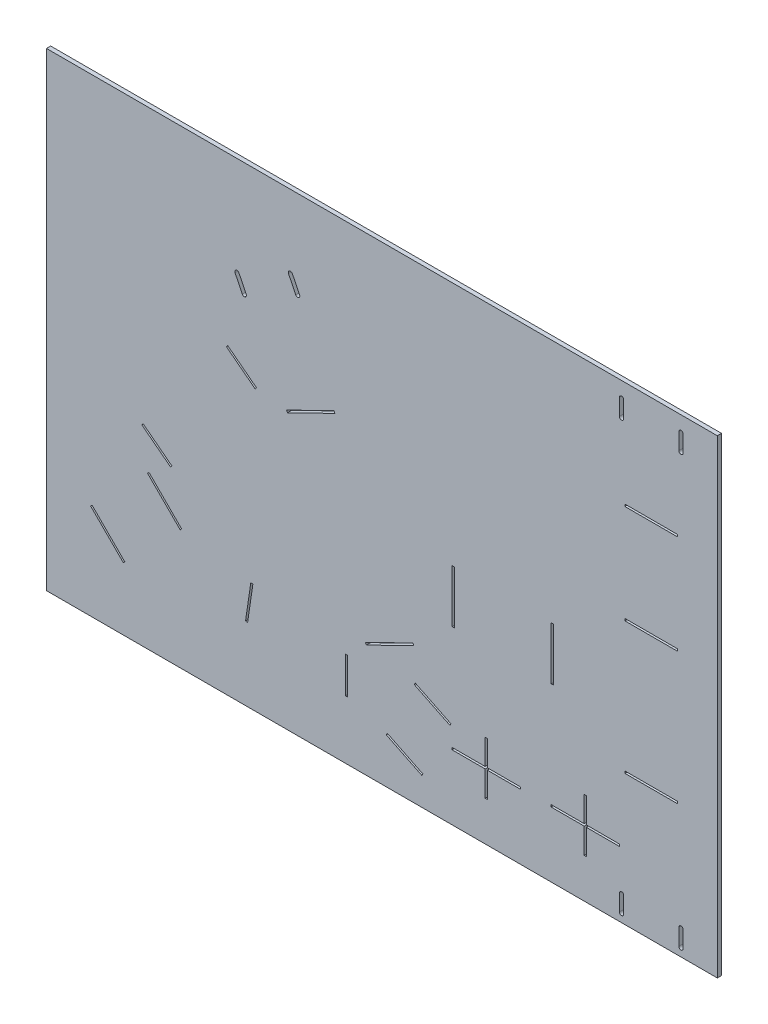
from build123d import *

# Parameters (mm, degrees)
SKETCH1_W           = 1016
SKETCH1_H           = 711.2
BOSS_EXTRUDE1_DEPTH = 6.35
SKETCH2_W           = 80
SKETCH2_H           = 3.175
SKETCH2_W_2         = 3.175
SKETCH2_H_2         = 80
CUT_EXTRUDE1_DEPTH  = 6.35
SKETCH3_W           = 50
SKETCH3_H           = 3.175
CUT_EXTRUDE2_DEPTH  = 10
CUT_EXTRUDE3_DEPTH  = 7.35
CUT_EXTRUDE4_DEPTH  = 7.35
CUT_EXTRUDE5_DEPTH  = 7.35
SKETCH8_W           = 3.175
SKETCH8_H           = 55
CUT_EXTRUDE6_DEPTH  = 7.35


with BuildPart() as part:
    # Sketch1 → Boss-Extrude1 (new body)
    with BuildSketch(Plane.XY):
        with Locations((508, -355.6)):
            Rectangle(SKETCH1_W, SKETCH1_H)
    extrude(amount=BOSS_EXTRUDE1_DEPTH)

    # Sketch2 → Cut-Extrude1 (cut)
    with BuildSketch(Plane.XY.offset(6.35)):
        with Locations((916, -161.2)):
            Rectangle(SKETCH2_W, SKETCH2_H)
        with Locations((916, -311.2)):
            Rectangle(SKETCH2_W, SKETCH2_H)
        with Locations((916, -511.2)):
            Rectangle(SKETCH2_W, SKETCH2_H)
        with Locations((766, -411.2)):
            Rectangle(SKETCH2_W_2, SKETCH2_H_2)
        with Locations((616, -411.2)):
            Rectangle(SKETCH2_W_2, SKETCH2_H_2)
        with BuildLine():
            Line((874.25, -673.7), (874.25, -698.7))
            ThreePointArc((874.25, -698.7), (871, -701.95), (867.75, -698.7))
            Line((867.75, -698.7), (867.75, -673.7))
            ThreePointArc((867.75, -673.7), (871, -670.45), (874.25, -673.7))
        make_face()
        Polygon((363.596651934, -292.488903378), (435.500175638, -257.419211635), (436.892004029, -260.272882732), (364.988480325, -295.342574475), align=None)
        Polygon((483.061726987, -537.428605693), (554.965250691, -502.35891395), (556.357079082, -505.212585047), (484.453555378, -540.28227679), align=None)
        with Locations((816, -611.2)):
            Rectangle(SKETCH2_W_2, SKETCH2_H_2)
        with Locations((666, -611.2)):
            Rectangle(SKETCH2_W_2, SKETCH2_H_2)
        Polygon((558.501253664, -553.109163281), (612.428896442, -579.411432089), (611.037068051, -582.265103186), (557.109425273, -555.962834378), align=None)
        Polygon((516.055967376, -640.134896814), (569.983610154, -666.437165622), (568.591781763, -669.290836719), (514.664138985, -642.988567911), align=None)
        Polygon((69.138539017, -564.561537688), (118.6360137, -614.059012371), (116.39094967, -616.304076401), (66.893474987, -566.806601718), align=None)
        Polygon((155.281822635, -478.418254069), (204.779297318, -527.915728753), (202.534233288, -530.160792783), (153.036758605, -480.6633181), align=None)
        with BuildLine():
            Line((964.25, -673.7), (964.25, -698.7))
            ThreePointArc((964.25, -698.7), (961, -701.95), (957.75, -698.7))
            Line((957.75, -698.7), (957.75, -673.7))
            ThreePointArc((957.75, -673.7), (961, -670.45), (964.25, -673.7))
        make_face()
        with BuildLine():
            Line((291.484365195, -148.62885591), (302.443643865, -171.098707067))
            ThreePointArc((302.443643865, -171.098707067), (300.947269442, -175.444493945), (296.601482564, -173.948119522))
            Line((296.601482564, -173.948119522), (285.642203894, -151.478268364))
            ThreePointArc((285.642203894, -151.478268364), (287.138578318, -147.132481487), (291.484365195, -148.62885591))
        make_face()
        with BuildLine():
            Line((372.375829362, -109.175452699), (383.335108032, -131.645303856))
            ThreePointArc((383.335108032, -131.645303856), (381.838733609, -135.991090734), (377.492946731, -134.494716311))
            Line((377.492946731, -134.494716311), (366.533668061, -112.024865153))
            ThreePointArc((366.533668061, -112.024865153), (368.030042485, -107.679078276), (372.375829362, -109.175452699))
        make_face()
        with BuildLine():
            Line((874.25, -23.7), (874.25, -48.7))
            ThreePointArc((874.25, -48.7), (871, -51.95), (867.75, -48.7))
            Line((867.75, -48.7), (867.75, -23.7))
            ThreePointArc((867.75, -23.7), (871, -20.45), (874.25, -23.7))
        make_face()
        with BuildLine():
            Line((957.75, -48.7), (957.75, -23.7))
            ThreePointArc((957.75, -23.7), (961, -20.45), (964.25, -23.7))
            Line((964.25, -23.7), (964.25, -48.7))
            ThreePointArc((964.25, -48.7), (961, -51.95), (957.75, -48.7))
        make_face()
    extrude(amount=-CUT_EXTRUDE1_DEPTH, mode=Mode.SUBTRACT)

    # Sketch3 → Cut-Extrude2 (cut)
    with BuildSketch(Plane.XY.offset(6.35)):
        with Locations((639.4125, -611.2)):
            Rectangle(SKETCH3_W, SKETCH3_H)
        with Locations((692.5875, -611.2)):
            Rectangle(SKETCH3_W, SKETCH3_H)
        with Locations((789.4125, -611.2)):
            Rectangle(SKETCH3_W, SKETCH3_H)
        with Locations((842.5875, -611.2)):
            Rectangle(SKETCH3_W, SKETCH3_H)
    extrude(amount=-CUT_EXTRUDE2_DEPTH, mode=Mode.SUBTRACT)

    # Sketch5 → Cut-Extrude3 (cut, through all)
    with BuildSketch(Plane.XY.offset(6.35)):
        Polygon((274.525666155, -252.511008661), (318.103646625, -286.066330417), (316.166589414, -288.58196838), (272.588608944, -255.026646624), align=None)
    extrude(amount=-CUT_EXTRUDE3_DEPTH, mode=Mode.SUBTRACT)

    # Sketch6 → Cut-Extrude4 (cut, through all)
    with BuildSketch(Plane.XY.offset(6.35)):
        Polygon((146.314409554, -418.997731493), (189.892390024, -452.553053249), (187.955332813, -455.068691213), (144.377352343, -421.513369457), align=None)
    extrude(amount=-CUT_EXTRUDE4_DEPTH, mode=Mode.SUBTRACT)

    # Sketch7 → Cut-Extrude5 (cut, through all)
    with BuildSketch(Plane.XY.offset(6.35)):
        Polygon((309.486197622, -545.854084542), (301.444635941, -600.263029448), (304.585515942, -600.727246872), (312.627077623, -546.318301967), align=None)
    extrude(amount=-CUT_EXTRUDE5_DEPTH, mode=Mode.SUBTRACT)

    # Sketch8 → Cut-Extrude6 (cut, through all)
    with BuildSketch(Plane.XY.offset(6.35)):
        with Locations((454.377367326, -595.36266963)):
            Rectangle(SKETCH8_W, SKETCH8_H)
    extrude(amount=-CUT_EXTRUDE6_DEPTH, mode=Mode.SUBTRACT)


solid = part.part
